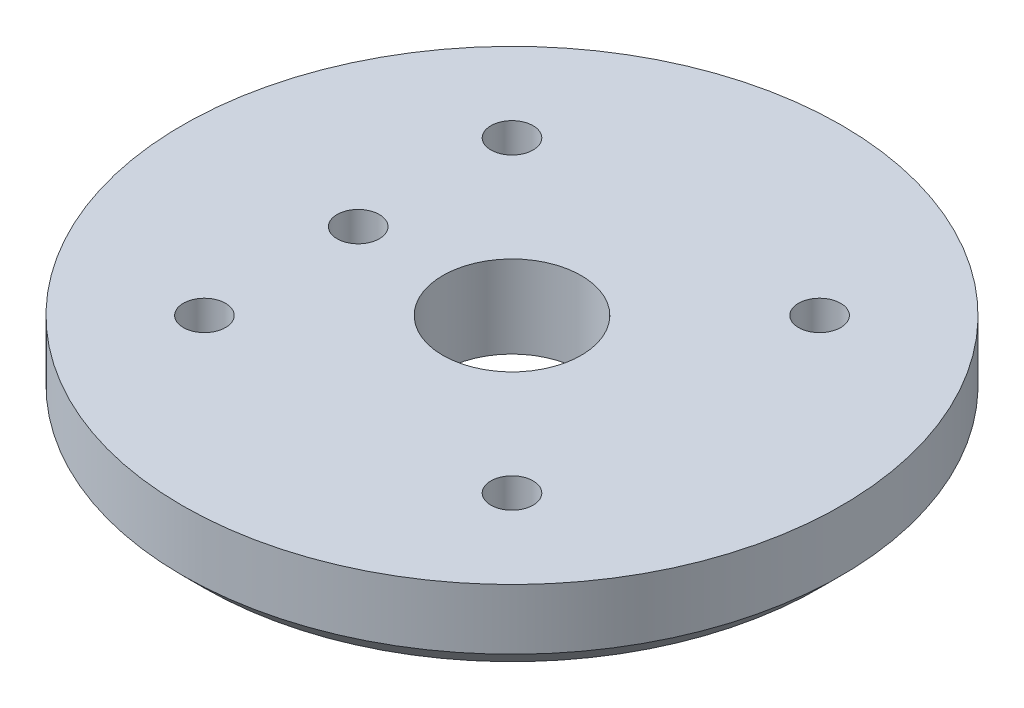
from build123d import *

# Parameters (mm, degrees)
SKETCH1_R                 = 19.05
SKETCH1_R_2               = 4
BOSS_EXTRUDE1_DEPTH       = 4.7625
F_2_CLEARANCE_HOLE1_D     = 2.4384
F_2_CLEARANCE_HOLE1_DEPTH = 4.7625
CHAMFER1_SIZE             = 1.27


with BuildPart() as part:
    # Sketch1 → Boss-Extrude1 (new body)
    with BuildSketch(Plane(origin=(0, 0, 0), x_dir=(1, 0, 0), z_dir=(0, 1, 0))):
        Circle(SKETCH1_R)
        Circle(SKETCH1_R_2, mode=Mode.SUBTRACT)
    extrude(amount=BOSS_EXTRUDE1_DEPTH)

    # #2 Clearance Hole1
    with Locations(Plane(origin=(0, 4.7625, 0), x_dir=(1, 0, 0), z_dir=(0, 1, 0))):
        with Locations((-8.89, 8.89), (8.89, 8.89), (-8.89, -8.89), (8.89, -8.89), (-8.89, 0)):
            Hole(F_2_CLEARANCE_HOLE1_D / 2, depth=F_2_CLEARANCE_HOLE1_DEPTH)

    # Chamfer1
    chamfer1_edges = [part.edges().sort_by_distance(p)[0] for p in [
        (-19.05, 0, 0),
    ]]
    chamfer(chamfer1_edges, length=CHAMFER1_SIZE)


solid = part.part
